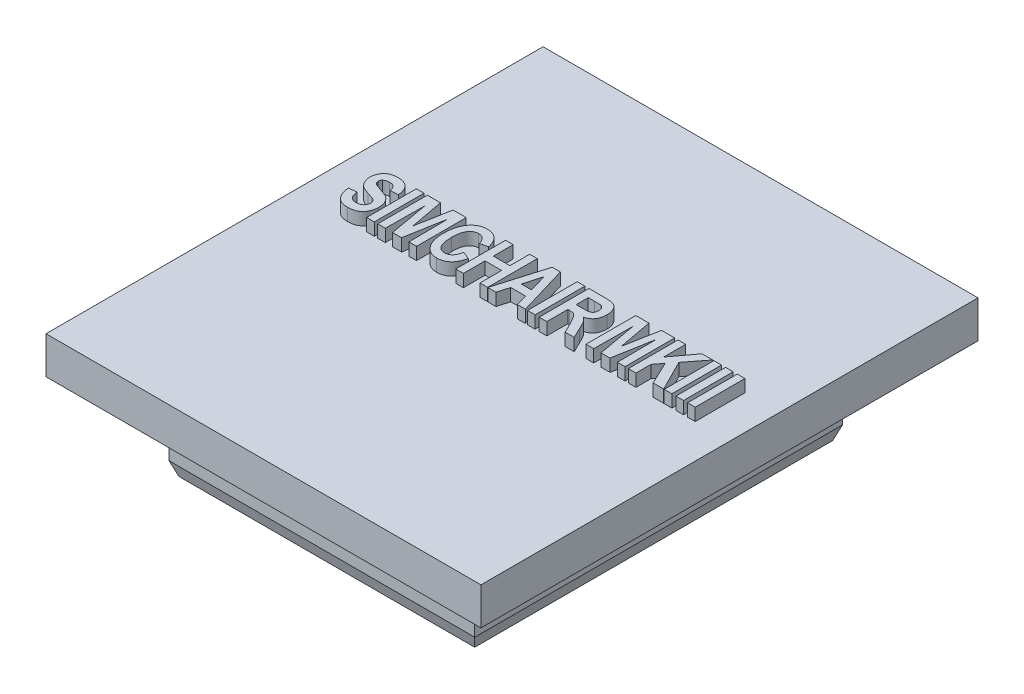
from build123d import *

# Parameters (mm, degrees)
SKETCH1_W           = 24.6
SKETCH1_H           = 29.6
BOSS_EXTRUDE1_DEPTH = 4
SKETCH2_W           = 35
SKETCH2_H           = 40
BOSS_EXTRUDE2_DEPTH = 3
CHAMFER1_SIZE       = 0.4
CHAMFER1_SIZE2      = 1.098990968
SKETCH3_W           = 0.615384615
SKETCH3_H           = 4
SKETCH3_W_2         = 0.615384616
BOSS_EXTRUDE3_DEPTH = 1


with BuildPart() as part:
    # Sketch1 → Boss-Extrude1 (new body)
    with BuildSketch(Plane(origin=(0, 0, 0), x_dir=(1, 0, 0), z_dir=(0, 1, 0))):
        Rectangle(SKETCH1_W, SKETCH1_H)
    extrude(amount=BOSS_EXTRUDE1_DEPTH)

    # Sketch2 → Boss-Extrude2 (add)
    with BuildSketch(Plane(origin=(0, 4, 0), x_dir=(1, 0, 0), z_dir=(0, 1, 0))):
        with Locations((-2.7, 3.2)):
            Rectangle(SKETCH2_W, SKETCH2_H)
    extrude(amount=BOSS_EXTRUDE2_DEPTH)

    # Chamfer1
    chamfer1_edges = [part.edges().sort_by_distance(p)[0] for p in [
        (0, 0, -14.8),
        (12.3, 0, 0),
        (0, 0, 14.8),
        (-12.3, 0, 0),
    ]]
    chamfer1_side = [part.faces().sort_by_distance(p)[0] for p in [
        (0, 0, 0),
    ]]
    chamfer(chamfer1_edges, length=CHAMFER1_SIZE, length2=CHAMFER1_SIZE2, reference=chamfer1_side[0])

    # Sketch3 → Boss-Extrude3 (add)
    with BuildSketch(Plane(origin=(0, 7, 0), x_dir=(1, 0, 0), z_dir=(0, 1, 0))):
        with BuildLine():
            Line((-17.184615385, 4.533333333), (-16.569230769, 4.584615385))
            add(Edge.make_bspline(
                [(-16.569230769, 4.584615385), (-16.564295602, 4.552487711), (-16.554744721, 4.490311992), (-16.534206318, 4.401126064), (-16.5114737, 4.318211558), (-16.48398832, 4.242072337), (-16.453902449, 4.171830357), (-16.419197823, 4.108510106), (-16.381902067, 4.051066841), (-16.339783205, 4.000911413), (-16.293684315, 3.957248903), (-16.243833488, 3.91957898), (-16.190501278, 3.887168363), (-16.133389987, 3.860459176), (-16.071931791, 3.840603885), (-16.006987199, 3.826335455), (-15.938339159, 3.817268074), (-15.89137489, 3.816022777), (-15.867307692, 3.815384615)],
                knots=[0, 0, 0, 0, 9.748e-05, 0.00018865, 0.000274391, 0.000355241, 0.000431313, 0.000503383, 0.00057161, 0.00063645, 0.000699364, 0.000761705, 0.000823544, 0.00088628, 0.000950387, 0.001016875, 0.001085551, 0.001157738, 0.001157738, 0.001157738, 0.001157738], degree=3))
            add(Edge.make_bspline(
                [(-15.867307692, 3.815384615), (-15.84190499, 3.81571842), (-15.792831722, 3.816363269), (-15.721637551, 3.824948107), (-15.654945054, 3.837111497), (-15.593482057, 3.855908749), (-15.536060641, 3.878088487), (-15.484258513, 3.906964748), (-15.437197821, 3.941178486), (-15.381277669, 3.991753561), (-15.323919927, 4.063642576), (-15.273090366, 4.158334548), (-15.240720144, 4.260423141), (-15.237520641, 4.331439291), (-15.235897436, 4.367467949)],
                knots=[0, 0, 0, 0, 7.616e-05, 0.000147126, 0.000214857, 0.00027925, 0.00033966, 0.000399198, 0.000456578, 0.000513874, 0.000624998, 0.00073039, 0.000835077, 0.000942878, 0.000942878, 0.000942878, 0.000942878], degree=3))
            add(Edge.make_bspline(
                [(-15.235897436, 4.367467949), (-15.236542178, 4.390241273), (-15.237797264, 4.434572864), (-15.251110948, 4.498209793), (-15.271658254, 4.556904891), (-15.302232001, 4.61020171), (-15.342772234, 4.659793461), (-15.395469796, 4.705198372), (-15.460588646, 4.747209344), (-15.509620223, 4.770305328), (-15.535576923, 4.782532051)],
                knots=[0, 0, 0, 0, 6.8227e-05, 0.000132813, 0.000194152, 0.000254082, 0.000316154, 0.000385427, 0.000461881, 0.000547884, 0.000547884, 0.000547884, 0.000547884], degree=3))
            add(Edge.make_bspline(
                [(-15.535576923, 4.782532051), (-15.546477956, 4.78720168), (-15.571207141, 4.797794814), (-15.61392787, 4.812205359), (-15.664980802, 4.830984668), (-15.725200989, 4.852020989), (-15.795049222, 4.873762835), (-15.873207923, 4.900011955), (-15.961129195, 4.926804242), (-16.022507897, 4.946202276), (-16.054807692, 4.956410256)],
                knots=[0, 0, 0, 0, 3.5565e-05, 8.0679e-05, 0.000135172, 0.000198777, 0.00027201, 0.000354616, 0.000446106, 0.00054773, 0.00054773, 0.00054773, 0.00054773], degree=3))
            add(Edge.make_bspline(
                [(-16.054807692, 4.956410256), (-16.096915659, 4.969532034), (-16.178343613, 4.994906793), (-16.293841718, 5.039935883), (-16.400555407, 5.084651649), (-16.49681275, 5.133183972), (-16.584219558, 5.182385163), (-16.660850591, 5.235302582), (-16.728606644, 5.289806609), (-16.767505489, 5.3296887), (-16.786378205, 5.349038462)],
                knots=[0, 0, 0, 0, 0.000132272, 0.000255787, 0.000371732, 0.000479235, 0.00057902, 0.000672368, 0.000758345, 0.000839369, 0.000839369, 0.000839369, 0.000839369], degree=3))
            add(Edge.make_bspline(
                [(-16.786378205, 5.349038462), (-16.809876394, 5.376671827), (-16.856424582, 5.431411497), (-16.916629579, 5.520356314), (-16.968356103, 5.6134677), (-17.010028396, 5.711556381), (-17.042124716, 5.814146251), (-17.065415729, 5.920826247), (-17.079199363, 6.032171441), (-17.081089337, 6.10781405), (-17.082051282, 6.146314103)],
                knots=[0, 0, 0, 0, 0.000108753, 0.000215432, 0.000321589, 0.000427855, 0.000534546, 0.00064362, 0.000755033, 0.000870518, 0.000870518, 0.000870518, 0.000870518], degree=3))
            add(Edge.make_bspline(
                [(-17.082051282, 6.146314103), (-17.080359481, 6.196109492), (-17.077016621, 6.294501079), (-17.050213748, 6.439475335), (-17.007840091, 6.579403948), (-16.948785304, 6.71328915), (-16.873484602, 6.836994514), (-16.782089109, 6.946893887), (-16.674648004, 7.039956864), (-16.552754792, 7.117518301), (-16.41612131, 7.177390315), (-16.266420707, 7.22078355), (-16.10323053, 7.246449487), (-15.989997986, 7.249634231), (-15.931410256, 7.251282051)],
                knots=[0, 0, 0, 0, 0.000149299, 0.000295002, 0.00044075, 0.000587113, 0.000732783, 0.00087385, 0.001014129, 0.001157505, 0.001305657, 0.00146008, 0.001623958, 0.00179966, 0.00179966, 0.00179966, 0.00179966], degree=3))
            add(Edge.make_bspline(
                [(-15.931410256, 7.251282051), (-15.883553564, 7.250498301), (-15.790520129, 7.24897469), (-15.655500947, 7.233200662), (-15.529279557, 7.209040947), (-15.412330392, 7.173876503), (-15.304968827, 7.127878156), (-15.206570168, 7.072343563), (-15.11664078, 7.007413521), (-15.037456099, 6.931288499), (-14.966673953, 6.847688077), (-14.904643309, 6.756636791), (-14.851995847, 6.658685862), (-14.80751747, 6.554448262), (-14.771998315, 6.443447822), (-14.747257643, 6.325213469), (-14.728687233, 6.200808938), (-14.724973164, 6.115400614), (-14.723076923, 6.071794872)],
                knots=[0, 0, 0, 0, 0.00014351, 0.000278984, 0.000407214, 0.000528631, 0.000644576, 0.000756885, 0.00086699, 0.000976379, 0.001085542, 0.00119511, 0.001306254, 0.001418622, 0.001534684, 0.001655231, 0.001780674, 0.001911529, 0.001911529, 0.001911529, 0.001911529], degree=3))
            Line((-14.723076923, 6.071794872), (-15.338461538, 6.020512821))
            add(Edge.make_bspline(
                [(-15.338461538, 6.020512821), (-15.342283137, 6.044579351), (-15.3497029, 6.091305342), (-15.363578107, 6.159017861), (-15.382454332, 6.220748139), (-15.401913623, 6.278062798), (-15.426443746, 6.329121255), (-15.452431208, 6.375980844), (-15.482209125, 6.417226883), (-15.526492573, 6.464592497), (-15.592492848, 6.514824193), (-15.688608661, 6.556128944), (-15.801156422, 6.580961768), (-15.881591087, 6.583350194), (-15.924198718, 6.584615385)],
                knots=[0, 0, 0, 0, 7.311e-05, 0.000141946, 0.000207106, 0.000266666, 0.000323302, 0.000376773, 0.00042726, 0.00047545, 0.000570964, 0.000673556, 0.000786889, 0.000914545, 0.000914545, 0.000914545, 0.000914545], degree=3))
            add(Edge.make_bspline(
                [(-15.924198718, 6.584615385), (-15.968688666, 6.583100927), (-16.053468513, 6.580214983), (-16.172980378, 6.553767431), (-16.277985043, 6.509165046), (-16.335774861, 6.464622534), (-16.364102564, 6.442788462)],
                knots=[0, 0, 0, 0, 0.000133305, 0.000254025, 0.000365241, 0.000472176, 0.000472176, 0.000472176, 0.000472176], degree=3))
            add(Edge.make_bspline(
                [(-16.364102564, 6.442788462), (-16.379916325, 6.427175482), (-16.411292782, 6.396197401), (-16.443485987, 6.337134735), (-16.46337184, 6.270995117), (-16.465544064, 6.22418923), (-16.466666667, 6.2)],
                knots=[0, 0, 0, 0, 6.6352e-05, 0.00013165, 0.000199343, 0.000271743, 0.000271743, 0.000271743, 0.000271743], degree=3))
            add(Edge.make_bspline(
                [(-16.466666667, 6.2), (-16.465845271, 6.177392018), (-16.464240772, 6.13322999), (-16.444059493, 6.070639052), (-16.415718951, 6.01162086), (-16.38686462, 5.978797356), (-16.372115385, 5.962019231)],
                knots=[0, 0, 0, 0, 6.7541e-05, 0.000131933, 0.00019572, 0.000262419, 0.000262419, 0.000262419, 0.000262419], degree=3))
            add(Edge.make_bspline(
                [(-16.372115385, 5.962019231), (-16.360613078, 5.951293605), (-16.335327538, 5.927715442), (-16.287889285, 5.896373279), (-16.230368896, 5.863694162), (-16.161971224, 5.83106434), (-16.083134725, 5.798505606), (-15.993885725, 5.764831432), (-15.893787517, 5.730285927), (-15.785125552, 5.697325702), (-15.674706571, 5.66462905), (-15.569705742, 5.628825714), (-15.471847816, 5.594189565), (-15.382039684, 5.557747296), (-15.299532913, 5.522108537), (-15.224805856, 5.485799013), (-15.157204178, 5.450273079), (-15.07833488, 5.400984506), (-14.988379727, 5.333861018), (-14.894416916, 5.238447984), (-14.812483025, 5.129619677), (-14.743493483, 5.007095058), (-14.687684216, 4.870275986), (-14.647895289, 4.718726297), (-14.624866454, 4.551935471), (-14.622003999, 4.435918897), (-14.620512821, 4.375480769)],
                knots=[0, 0, 0, 0, 4.7112e-05, 0.000103567, 0.000169958, 0.000245576, 0.000330697, 0.000425793, 0.000531714, 0.0006483, 0.000766418, 0.000877148, 0.000981068, 0.001077785, 0.00116785, 0.001250634, 0.001326992, 0.001396809, 0.001529503, 0.001662653, 0.001797109, 0.001937047, 0.002083315, 0.002239193, 0.002405885, 0.002587152, 0.002587152, 0.002587152, 0.002587152], degree=3))
            add(Edge.make_bspline(
                [(-14.620512821, 4.375480769), (-14.622361548, 4.319270172), (-14.626012131, 4.208274087), (-14.655192721, 4.044436315), (-14.702308066, 3.886248894), (-14.757451976, 3.760141641), (-14.809023361, 3.663752468), (-14.853522793, 3.596811663), (-14.900348077, 3.533729292), (-14.952717155, 3.476709665), (-15.007244384, 3.422706213), (-15.067064679, 3.37489706), (-15.129888991, 3.330901945), (-15.197209158, 3.292850997), (-15.268438241, 3.2588852), (-15.34360987, 3.229208958), (-15.423294069, 3.204669629), (-15.506909664, 3.183502228), (-15.595016948, 3.167740399), (-15.687310173, 3.156554116), (-15.78388581, 3.15023608), (-15.849670516, 3.149231834), (-15.883333333, 3.148717949)],
                knots=[0, 0, 0, 0, 0.000168544, 0.000332814, 0.000497594, 0.000662676, 0.000744787, 0.000825239, 0.000903605, 0.000980198, 0.001057262, 0.001133599, 0.001209615, 0.001287137, 0.001365269, 0.001446215, 0.00152934, 0.001615238, 0.001704824, 0.001797651, 0.001894019, 0.001995009, 0.001995009, 0.001995009, 0.001995009], degree=3))
            add(Edge.make_bspline(
                [(-15.883333333, 3.148717949), (-15.931735049, 3.149701269), (-16.02590826, 3.151614475), (-16.162830804, 3.169153494), (-16.291318423, 3.195552406), (-16.411078013, 3.234428883), (-16.522291182, 3.283981898), (-16.62489728, 3.345515062), (-16.718954443, 3.417622517), (-16.803958985, 3.50127415), (-16.879914164, 3.59549528), (-16.948399483, 3.699566807), (-17.008745764, 3.81377781), (-17.059385106, 3.938706205), (-17.103761963, 4.072973056), (-17.139600497, 4.217329355), (-17.166695199, 4.37189743), (-17.1785287, 4.478500787), (-17.184615385, 4.533333333)],
                knots=[0, 0, 0, 0, 0.00014514, 0.000282394, 0.000413462, 0.000538132, 0.000659357, 0.000777949, 0.000896227, 0.001014084, 0.001134846, 0.001258633, 0.001387311, 0.00152168, 0.001662565, 0.001811234, 0.001967474, 0.002132954, 0.002132954, 0.002132954, 0.002132954], degree=3))
        make_face()
        with Locations((-14.092307693, 5.2)):
            Rectangle(SKETCH3_W, SKETCH3_H)
        Polygon((-13.512820513, 3.2), (-13.512820513, 7.2), (-12.455929487, 7.2), (-11.948717949, 4.471634615), (-11.44150641, 7.2), (-10.384615385, 7.2), (-10.384615385, 3.2), (-11, 3.2), (-11.025641026, 6.349038462), (-11.586538462, 3.2), (-12.310897436, 3.2), (-12.871794872, 6.349038462), (-12.897435897, 3.2), align=None)
        with BuildLine():
            Line((-8.061538462, 4.687179487), (-7.446153846, 4.430769231))
            add(Edge.make_bspline(
                [(-7.446153846, 4.430769231), (-7.458340202, 4.380380994), (-7.482126517, 4.282029153), (-7.527557301, 4.140974203), (-7.577398568, 4.009175749), (-7.634414027, 3.887939411), (-7.697078202, 3.776773646), (-7.765203288, 3.675114492), (-7.839687313, 3.583535131), (-7.920350962, 3.502144588), (-8.006149091, 3.430254896), (-8.098590114, 3.369007345), (-8.196238443, 3.316862414), (-8.299692829, 3.274396631), (-8.408087424, 3.240151059), (-8.522877397, 3.217618156), (-8.642870052, 3.202583844), (-8.7249523, 3.200870649), (-8.766666667, 3.2)],
                knots=[0, 0, 0, 0, 0.000155473, 0.000303466, 0.000444238, 0.00057794, 0.000704958, 0.000826744, 0.000944631, 0.001058517, 0.001170037, 0.001279821, 0.001390587, 0.001501595, 0.001614883, 0.001731013, 0.001852068, 0.00197716, 0.00197716, 0.00197716, 0.00197716], degree=3))
            add(Edge.make_bspline(
                [(-8.766666667, 3.2), (-8.818334542, 3.201325844), (-8.919933311, 3.203932959), (-9.068554184, 3.230937294), (-9.210306923, 3.272408211), (-9.345604678, 3.330269339), (-9.472577502, 3.406627997), (-9.592980561, 3.498563726), (-9.705433479, 3.608046943), (-9.810899001, 3.732450531), (-9.906050062, 3.87215591), (-9.989515308, 4.024470741), (-10.059166293, 4.189542555), (-10.117131154, 4.366025278), (-10.160568774, 4.555515568), (-10.192399366, 4.756546531), (-10.211966802, 4.969912892), (-10.214224673, 5.116089936), (-10.215384615, 5.191185897)],
                knots=[0, 0, 0, 0, 0.000154855, 0.000304504, 0.000451556, 0.000597277, 0.000744591, 0.000894918, 0.001050757, 0.001214501, 0.001383412, 0.00155697, 0.001734676, 0.001920159, 0.002113549, 0.002317208, 0.002530417, 0.002755669, 0.002755669, 0.002755669, 0.002755669], degree=3))
            add(Edge.make_bspline(
                [(-10.215384615, 5.191185897), (-10.214214625, 5.270286009), (-10.211934235, 5.4244575), (-10.192529163, 5.648758785), (-10.160791027, 5.859771133), (-10.116279099, 6.057034138), (-10.058971184, 6.241009617), (-9.987000598, 6.410673565), (-9.904276873, 6.567823072), (-9.807769637, 6.709780182), (-9.701162917, 6.83680038), (-9.585851965, 6.947775464), (-9.462131888, 7.042089041), (-9.330029543, 7.118373413), (-9.189984802, 7.178483738), (-9.041699505, 7.220960729), (-8.885040002, 7.246045615), (-8.777976023, 7.249513969), (-8.723397436, 7.251282051)],
                knots=[0, 0, 0, 0, 0.000237266, 0.000462448, 0.000674816, 0.000876974, 0.00106856, 0.001252055, 0.001429138, 0.001600487, 0.001765973, 0.001925788, 0.002079636, 0.002231502, 0.002382273, 0.002535703, 0.002693124, 0.002856823, 0.002856823, 0.002856823, 0.002856823], degree=3))
            add(Edge.make_bspline(
                [(-8.723397436, 7.251282051), (-8.675790515, 7.249798321), (-8.582285928, 7.24688413), (-8.445109042, 7.22682748), (-8.315190325, 7.192191248), (-8.191736303, 7.14480878), (-8.07580124, 7.082408471), (-7.96641112, 7.006687539), (-7.863600715, 6.917471314), (-7.803036598, 6.848707628), (-7.772275641, 6.813782051)],
                knots=[0, 0, 0, 0, 0.00014281, 0.000280493, 0.000414796, 0.000545444, 0.000676289, 0.00080876, 0.000943913, 0.00108341, 0.00108341, 0.00108341, 0.00108341], degree=3))
            add(Edge.make_bspline(
                [(-7.772275641, 6.813782051), (-7.754215965, 6.791393727), (-7.717351007, 6.745692759), (-7.669139782, 6.66965727), (-7.623131506, 6.587664978), (-7.58058295, 6.498255282), (-7.541794867, 6.401481553), (-7.505607983, 6.298115855), (-7.473418454, 6.187608326), (-7.455418014, 6.111146815), (-7.446153846, 6.071794872)],
                knots=[0, 0, 0, 0, 8.623e-05, 0.00017602, 0.000269647, 0.000368208, 0.000472811, 0.000582285, 0.000696644, 0.000817913, 0.000817913, 0.000817913, 0.000817913], degree=3))
            Line((-7.446153846, 6.071794872), (-8.061538462, 5.917948718))
            add(Edge.make_bspline(
                [(-8.061538462, 5.917948718), (-8.072669067, 5.967238219), (-8.094127272, 6.062261276), (-8.148567063, 6.194176129), (-8.219793561, 6.309161466), (-8.291609596, 6.392269806), (-8.356472299, 6.447906482), (-8.406712791, 6.485472676), (-8.460670658, 6.51553373), (-8.516703637, 6.540694391), (-8.574996909, 6.561114931), (-8.636694936, 6.574153635), (-8.700396691, 6.583703158), (-8.743926435, 6.584309692), (-8.765865385, 6.584615385)],
                knots=[0, 0, 0, 0, 0.000151394, 0.000291865, 0.000425725, 0.000555752, 0.000619372, 0.000681877, 0.000743597, 0.000804209, 0.000866038, 0.00092844, 0.000993146, 0.001058895, 0.001058895, 0.001058895, 0.001058895], degree=3))
            add(Edge.make_bspline(
                [(-8.765865385, 6.584615385), (-8.796122333, 6.583816971), (-8.855700221, 6.582244842), (-8.942412229, 6.56610578), (-9.025281315, 6.542452458), (-9.10369167, 6.507562722), (-9.177269342, 6.462279333), (-9.247225147, 6.408331543), (-9.311104992, 6.343200234), (-9.372048104, 6.269547962), (-9.425672463, 6.183473478), (-9.473255241, 6.086215996), (-9.51186707, 5.975977986), (-9.544843251, 5.854489104), (-9.568902339, 5.720356888), (-9.587637049, 5.574387776), (-9.597390583, 5.415943196), (-9.599111147, 5.306314353), (-9.6, 5.249679487)],
                knots=[0, 0, 0, 0, 9.0672e-05, 0.00017854, 0.000263732, 0.000348751, 0.000435052, 0.000522407, 0.000613061, 0.000708171, 0.000808651, 0.000916518, 0.00103235, 0.001158498, 0.00129381, 0.001440803, 0.001599799, 0.001769718, 0.001769718, 0.001769718, 0.001769718], degree=3))
            add(Edge.make_bspline(
                [(-9.6, 5.249679487), (-9.599629126, 5.189556449), (-9.598914677, 5.073736046), (-9.58667638, 4.907010389), (-9.571203868, 4.753227246), (-9.545921092, 4.613141451), (-9.515813086, 4.485675698), (-9.475995398, 4.372659159), (-9.431882097, 4.271642252), (-9.378448556, 4.184709532), (-9.319508293, 4.109697444), (-9.256613975, 4.044979588), (-9.189675251, 3.989730947), (-9.118310987, 3.944780479), (-9.042644299, 3.909676788), (-8.962619088, 3.88495272), (-8.878400015, 3.869146729), (-8.820690144, 3.86749961), (-8.79150641, 3.866666667)],
                knots=[0, 0, 0, 0, 0.000180317, 0.000347361, 0.000501328, 0.000643735, 0.000774138, 0.000893746, 0.001002768, 0.001104186, 0.001198921, 0.001288449, 0.001374426, 0.001458682, 0.001540782, 0.001623907, 0.001709408, 0.00179688, 0.00179688, 0.00179688, 0.00179688], degree=3))
            add(Edge.make_bspline(
                [(-8.79150641, 3.866666667), (-8.769852724, 3.867377115), (-8.726902217, 3.868786304), (-8.663560335, 3.877138641), (-8.602887753, 3.893943372), (-8.544522329, 3.915241786), (-8.488159808, 3.942834582), (-8.434861184, 3.977566902), (-8.383147352, 4.017786863), (-8.334160559, 4.06436795), (-8.288284342, 4.117959523), (-8.244798912, 4.177915436), (-8.205791578, 4.245878029), (-8.169689825, 4.320233772), (-8.137835356, 4.402188508), (-8.108166663, 4.490556754), (-8.082583741, 4.586437392), (-8.068695562, 4.652919011), (-8.061538462, 4.687179487)],
                knots=[0, 0, 0, 0, 6.4983e-05, 0.000128895, 0.000191091, 0.000253457, 0.000315094, 0.000378885, 0.000443962, 0.000511408, 0.000581285, 0.000655337, 0.00073326, 0.000816044, 0.000903089, 0.000996843, 0.001095583, 0.001200572, 0.001200572, 0.001200572, 0.001200572], degree=3))
        make_face()
        Polygon((-7.225641026, 3.2), (-7.225641026, 7.2), (-6.61025641, 7.2), (-6.61025641, 5.61025641), (-5.276923077, 5.61025641), (-5.276923077, 7.2), (-4.661538462, 7.2), (-4.661538462, 3.2), (-5.276923077, 3.2), (-5.276923077, 4.943589744), (-6.61025641, 4.943589744), (-6.61025641, 3.2), align=None)
        Polygon((-1.620512821, 3.2), (-2.27275641, 3.2), (-2.534775641, 4.123076923), (-3.726282051, 4.123076923), (-3.985897436, 3.2), (-4.646153846, 3.2), (-3.465064103, 7.2), (-2.811217949, 7.2), align=None)
        Polygon((-2.724679487, 4.78974359), (-3.133333333, 6.225641026), (-3.537980769, 4.78974359), align=None, mode=Mode.SUBTRACT)
        with Locations((-1.143589744, 5.2)):
            Rectangle(SKETCH3_W, SKETCH3_H)
        with BuildLine():
            Line((-0.512820513, 3.2), (-0.512820513, 7.2))
            Line((-0.512820513, 7.2), (0.819711538, 7.2))
            add(Edge.make_bspline(
                [(0.819711538, 7.2), (0.860045058, 7.199680732), (0.938071781, 7.199063097), (1.050906028, 7.194679071), (1.155053676, 7.185394875), (1.250913665, 7.174887227), (1.338082948, 7.159600325), (1.416825816, 7.141431484), (1.48685012, 7.120041999), (1.549080329, 7.094838409), (1.605677101, 7.065309379), (1.658735002, 7.030932129), (1.708387457, 6.990340139), (1.755769833, 6.94556767), (1.800227309, 6.895588247), (1.840804547, 6.839894669), (1.879551337, 6.779532985), (1.927523027, 6.691868806), (1.977952096, 6.573486563), (2.020160246, 6.421260946), (2.046319925, 6.259661926), (2.049604957, 6.14855163), (2.051282051, 6.091826923)],
                knots=[0, 0, 0, 0, 0.000121004, 0.000234087, 0.000338626, 0.000434636, 0.000523293, 0.000603952, 0.000676944, 0.000742712, 0.000805074, 0.000868192, 0.000932014, 0.000997194, 0.001063604, 0.001132355, 0.001203705, 0.001278654, 0.00143195, 0.001588463, 0.001751549, 0.00192165, 0.00192165, 0.00192165, 0.00192165], degree=3))
            add(Edge.make_bspline(
                [(2.051282051, 6.091826923), (2.050603033, 6.05548854), (2.049277888, 5.984572), (2.040772821, 5.880338558), (2.024432745, 5.781128208), (2.003015154, 5.686586167), (1.97588907, 5.596577978), (1.941378417, 5.512039216), (1.900946617, 5.431909465), (1.854992731, 5.356597456), (1.801765665, 5.287599748), (1.743028707, 5.224486437), (1.678023616, 5.168314528), (1.606734859, 5.119109839), (1.52958465, 5.076308211), (1.445777652, 5.041507402), (1.35636345, 5.012098752), (1.293951212, 4.998582162), (1.262019231, 4.991666667)],
                knots=[0, 0, 0, 0, 0.000109021, 0.000212762, 0.000313405, 0.0004104, 0.000503421, 0.00059508, 0.00068395, 0.000772454, 0.000859318, 0.000944921, 0.001030703, 0.0011165, 0.001204367, 0.001294852, 0.001388355, 0.001486312, 0.001486312, 0.001486312, 0.001486312], degree=3))
            add(Edge.make_bspline(
                [(1.262019231, 4.991666667), (1.293423855, 4.965699372), (1.355262058, 4.914567703), (1.43948382, 4.830754111), (1.515204932, 4.74308879), (1.572325766, 4.665387424), (1.616758634, 4.597481275), (1.65151231, 4.537143958), (1.689945278, 4.468214309), (1.731788401, 4.390835845), (1.774845655, 4.303627056), (1.821149639, 4.207657042), (1.870979316, 4.102876199), (1.90422899, 4.029647611), (1.921474359, 3.991666667)],
                knots=[0, 0, 0, 0, 0.000122197, 0.000240617, 0.000355948, 0.000469414, 0.000529643, 0.000599318, 0.000678235, 0.000766424, 0.000863177, 0.000969973, 0.001086103, 0.001211239, 0.001211239, 0.001211239, 0.001211239], degree=3))
            Line((1.921474359, 3.991666667), (2.307692308, 3.2))
            Line((2.307692308, 3.2), (1.581730769, 3.2))
            Line((1.581730769, 3.2), (1.137019231, 4.090224359))
            add(Edge.make_bspline(
                [(1.137019231, 4.090224359), (1.116174719, 4.127343946), (1.076416274, 4.198145172), (1.019896786, 4.299204899), (0.967623233, 4.389115346), (0.920556355, 4.468148093), (0.87875892, 4.536612858), (0.842340032, 4.594355392), (0.810085519, 4.640810737), (0.775908497, 4.688104955), (0.735448102, 4.735817073), (0.684889253, 4.782325009), (0.63329537, 4.82007557), (0.577769151, 4.848851554), (0.513403512, 4.869343273), (0.435898791, 4.883146835), (0.342815475, 4.89031307), (0.275652409, 4.891610776), (0.239583333, 4.892307692)],
                knots=[0, 0, 0, 0, 0.000127716, 0.000243603, 0.000347365, 0.000439711, 0.000519554, 0.000588016, 0.000644471, 0.000689185, 0.000763059, 0.000831675, 0.000894829, 0.000954319, 0.001018427, 0.00109669, 0.001189984, 0.001298204, 0.001298204, 0.001298204, 0.001298204], degree=3))
            Line((0.239583333, 4.892307692), (0.102564103, 4.892307692))
            Line((0.102564103, 4.892307692), (0.102564103, 3.2))
            Line((0.102564103, 3.2), (-0.512820513, 3.2))
        make_face()
        with BuildLine():
            Line((0.102564103, 5.558974359), (0.590544872, 5.558974359))
            add(Edge.make_bspline(
                [(0.590544872, 5.558974359), (0.628207997, 5.559078724), (0.70007029, 5.559277856), (0.802090151, 5.562084902), (0.893249027, 5.56451548), (0.972817886, 5.570518591), (1.041553306, 5.576550677), (1.09884756, 5.584214771), (1.145282304, 5.593519336), (1.191990774, 5.608054776), (1.239957497, 5.632832677), (1.290795839, 5.668804216), (1.333376064, 5.715080796), (1.370881932, 5.768281415), (1.400258507, 5.830055215), (1.420978632, 5.899503993), (1.434010337, 5.975685683), (1.435254301, 6.029004469), (1.435897436, 6.056570513)],
                knots=[0, 0, 0, 0, 0.000112984, 0.000215576, 0.000306177, 0.000386502, 0.000454912, 0.000513158, 0.000559832, 0.00059683, 0.00065954, 0.000720926, 0.000782708, 0.00084717, 0.000915622, 0.000986846, 0.00106404, 0.001146669, 0.001146669, 0.001146669, 0.001146669], degree=3))
            add(Edge.make_bspline(
                [(1.435897436, 6.056570513), (1.434800575, 6.087343121), (1.432695461, 6.146402438), (1.417357198, 6.230598684), (1.38860174, 6.30486549), (1.350064734, 6.370110979), (1.300793694, 6.424781442), (1.242519108, 6.469617078), (1.174219094, 6.501645796), (1.124724134, 6.51412003), (1.099358974, 6.520512821)],
                knots=[0, 0, 0, 0, 9.2318e-05, 0.000177178, 0.000255302, 0.000330058, 0.000403256, 0.000474732, 0.000549281, 0.000627647, 0.000627647, 0.000627647, 0.000627647], degree=3))
            add(Edge.make_bspline(
                [(1.099358974, 6.520512821), (1.091089761, 6.521688869), (1.071153075, 6.524524267), (1.036054572, 6.526194826), (0.990954328, 6.529035806), (0.935626806, 6.530101161), (0.870204484, 6.532090912), (0.794869954, 6.532441195), (0.709671798, 6.53360101), (0.64957325, 6.533425929), (0.617788462, 6.533333333)],
                knots=[0, 0, 0, 0, 2.5046e-05, 6.0384e-05, 0.00010532, 0.000160632, 0.000226356, 0.000301681, 0.000386621, 0.000481973, 0.000481973, 0.000481973, 0.000481973], degree=3))
            Line((0.617788462, 6.533333333), (0.102564103, 6.533333333))
            Line((0.102564103, 6.533333333), (0.102564103, 5.558974359))
        make_face(mode=Mode.SUBTRACT)
        Polygon((3.261538462, 3.2), (3.261538462, 7.2), (4.318429487, 7.2), (4.825641026, 4.471634615), (5.332852564, 7.2), (6.38974359, 7.2), (6.38974359, 3.2), (5.774358974, 3.2), (5.748717949, 6.349038462), (5.187820513, 3.2), (4.463461538, 3.2), (3.902564103, 6.349038462), (3.876923077, 3.2), align=None)
        Polygon((6.661538462, 3.2), (6.661538462, 7.2), (7.276923077, 7.2), (7.276923077, 5.426762821), (8.595032051, 7.2), (9.456410256, 7.2), (8.260897436, 5.667147436), (9.507692308, 3.2), (8.657532051, 3.2), (7.779326923, 5.050160256), (7.276923077, 4.405929487), (7.276923077, 3.2), align=None)
        with Locations((9.856410257, 5.2)):
            Rectangle(SKETCH3_W, SKETCH3_H)
        with Locations((10.794871795, 5.2)):
            Rectangle(SKETCH3_W_2, SKETCH3_H)
        with Locations((11.733333334, 5.2)):
            Rectangle(SKETCH3_W, SKETCH3_H)
    extrude(amount=BOSS_EXTRUDE3_DEPTH)


solid = part.part
